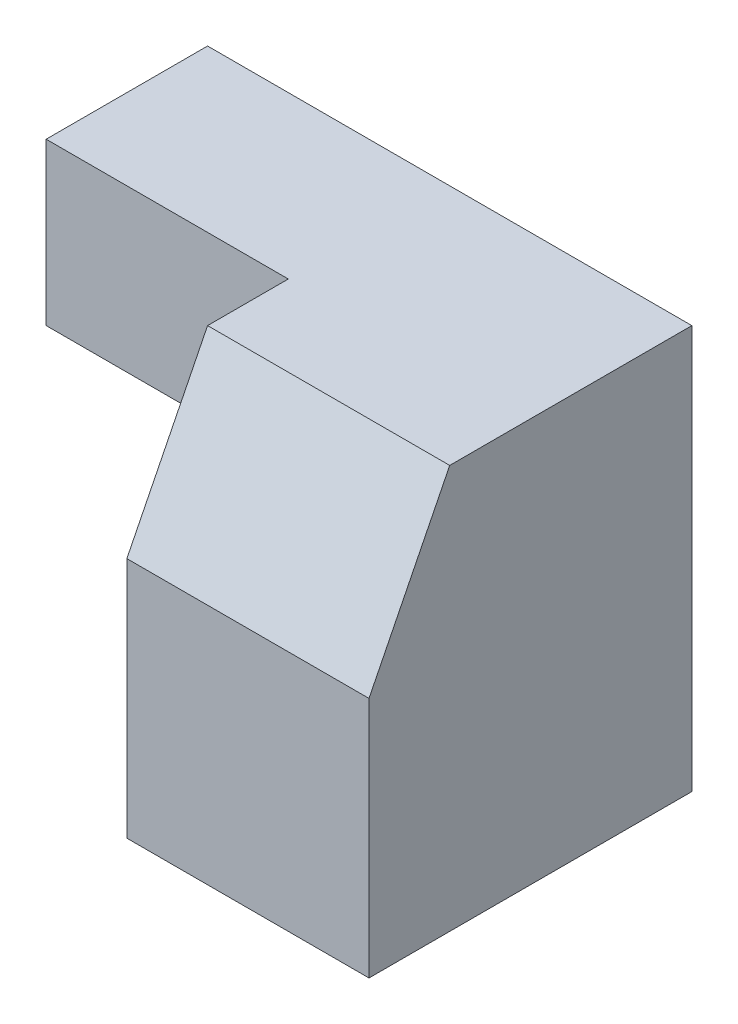
from build123d import *

# Parameters (mm, degrees)
SKETCH1_W           = 30
SKETCH1_H           = 25
BOSS_EXTRUDE1_DEPTH = 20
SKETCH2_W           = 15
SKETCH2_H           = 25
CUT_EXTRUDE1_DEPTH  = 10
CUT_EXTRUDE2_DEPTH  = 20
SKETCH4_W           = 10
SKETCH4_H           = 15
CUT_EXTRUDE3_DEPTH  = 15


with BuildPart() as part:
    # Sketch1 → Boss-Extrude1 (new body)
    with BuildSketch(Plane.XY):
        with Locations((15, 12.5)):
            Rectangle(SKETCH1_W, SKETCH1_H)
    extrude(amount=BOSS_EXTRUDE1_DEPTH)

    # Sketch2 → Cut-Extrude1 (cut)
    with BuildSketch(Plane.XY.offset(20)):
        with Locations((7.5, 12.5)):
            Rectangle(SKETCH2_W, SKETCH2_H)
    extrude(amount=-CUT_EXTRUDE1_DEPTH, mode=Mode.SUBTRACT)

    # Sketch3 → Cut-Extrude2 (cut)
    with BuildSketch(Plane.ZY.offset(-15)):
        Polygon((15, 25), (20, 15), (20, 25), align=None)
    extrude(amount=-CUT_EXTRUDE2_DEPTH, mode=Mode.SUBTRACT)

    # Sketch4 → Cut-Extrude3 (cut)
    with BuildSketch(Plane.ZY):
        with Locations((5, 7.5)):
            Rectangle(SKETCH4_W, SKETCH4_H)
    extrude(amount=-CUT_EXTRUDE3_DEPTH, mode=Mode.SUBTRACT)


solid = part.part
